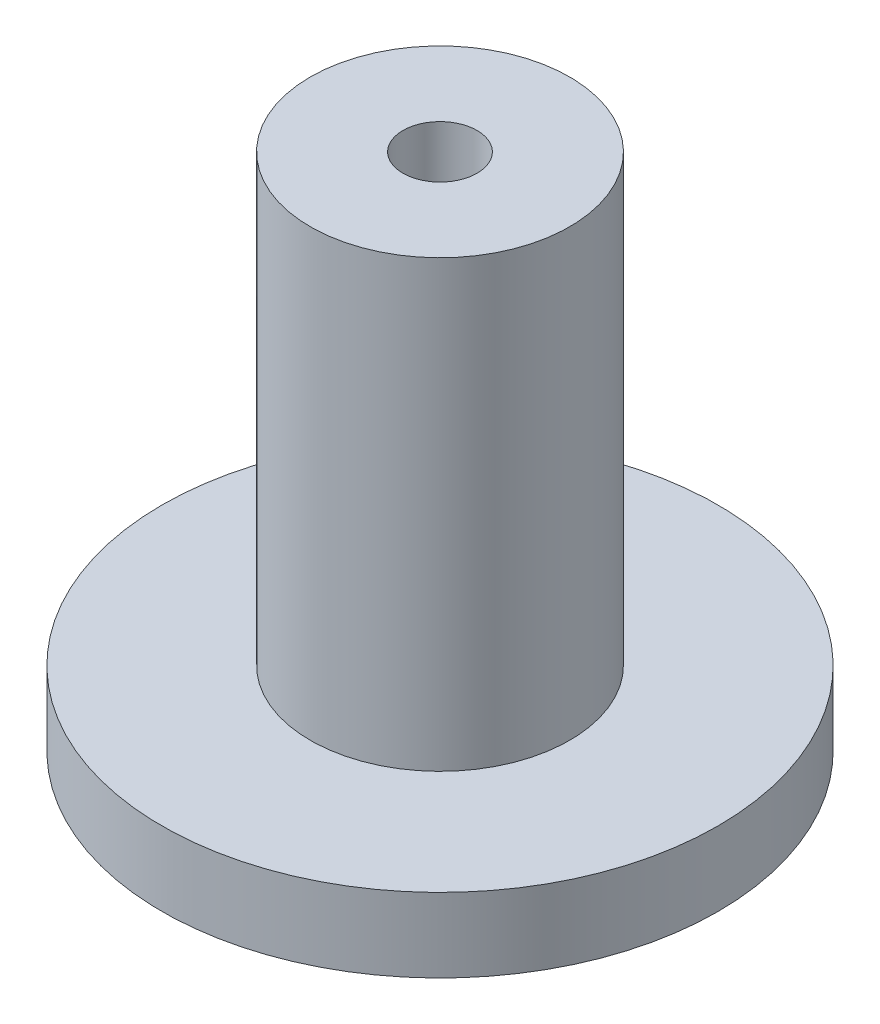
from build123d import *


with BuildPart() as part:
    # Sketch1 → Revolve1 (revolve)
    with BuildSketch(Plane.XY):
        Polygon((11.90625, 0), (2.38125, 0), (2.38125, 19.05), (1.5875, 19.05), (1.5875, 22.225), (5.55625, 22.225), (5.55625, 3.175), (11.90625, 3.175), align=None)
    revolve(axis=Axis((0, 6.318301654, 0), (0, -1, 0)))


solid = part.part
